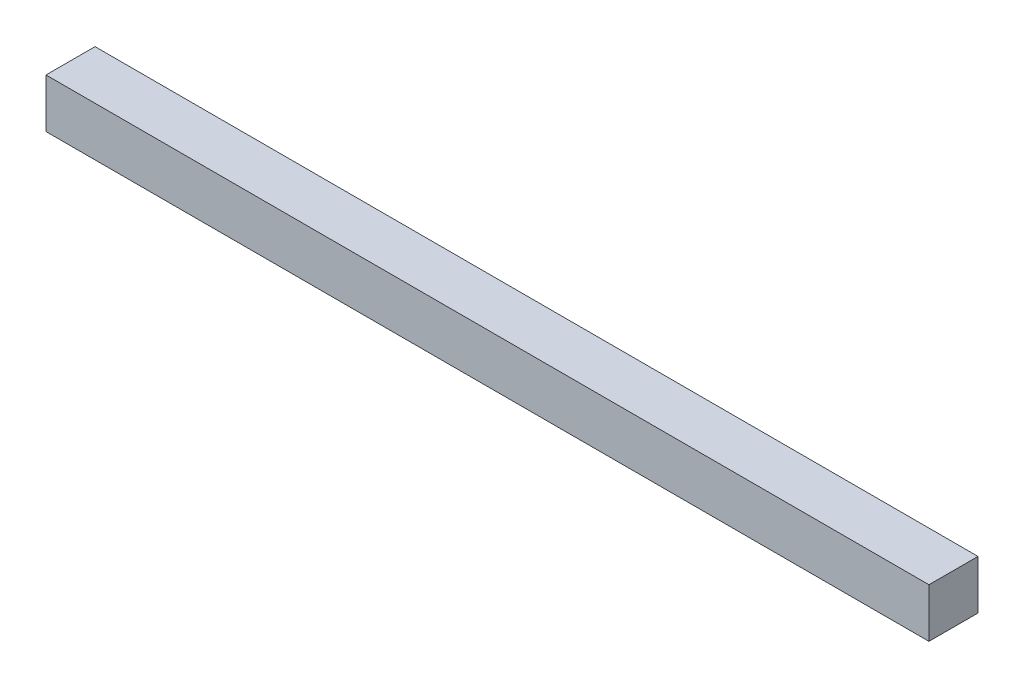
from build123d import *

# Parameters (mm, degrees)
SKETCH1_W           = 38.1
SKETCH1_H           = 38.1
BOSS_EXTRUDE1_DEPTH = 685.8


with BuildPart() as part:
    # Sketch1 → Boss-Extrude1 (new body)
    with BuildSketch(Plane(origin=(0, 0, 0), x_dir=(0, 0, -1), z_dir=(1, 0, 0))):
        Rectangle(SKETCH1_W, SKETCH1_H)
    extrude(amount=BOSS_EXTRUDE1_DEPTH)


solid = part.part
